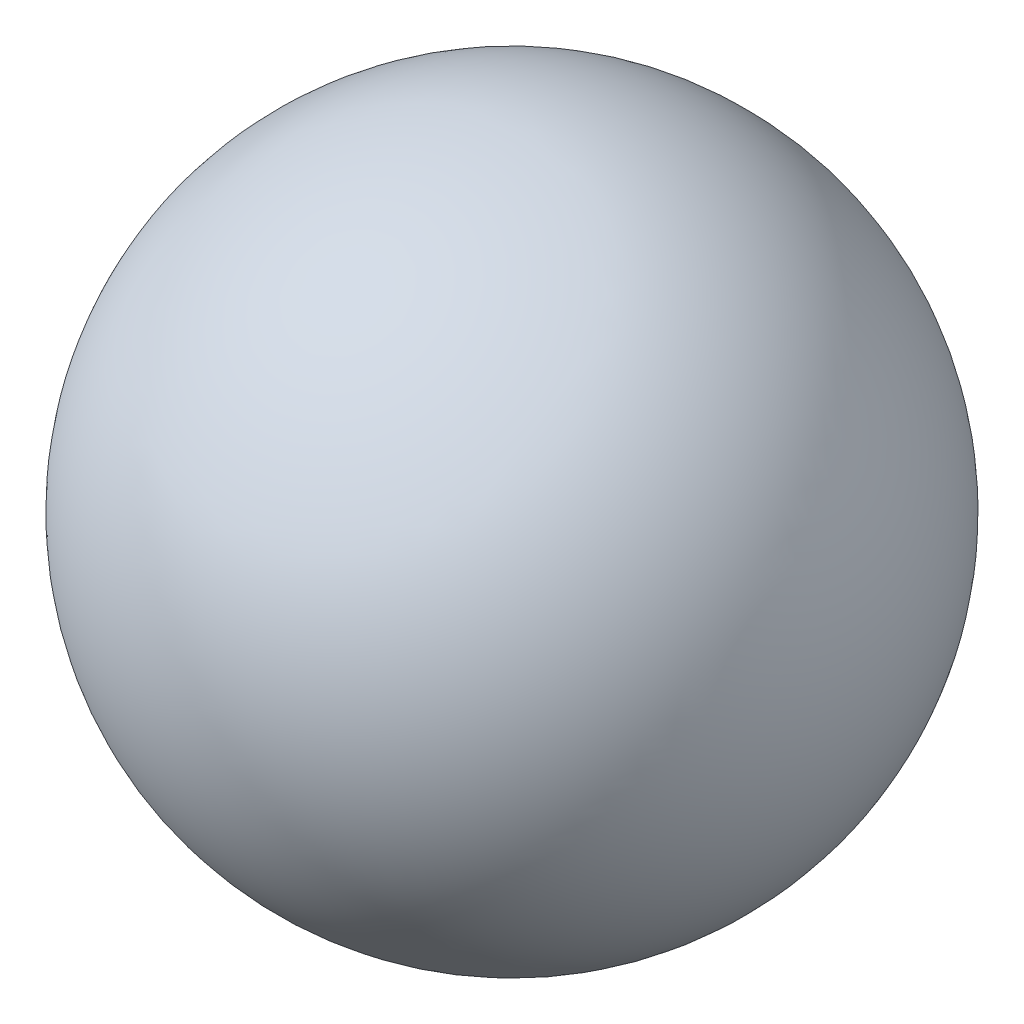
from build123d import *


with BuildPart() as part:
    # Sketch1 → Revolve2 (revolve)
    with BuildSketch(Plane.XY):
        with BuildLine():
            Line((0, 0), (0, 19))
            ThreePointArc((0, 19), (13.435028843, 13.435028843), (19, 0))
            Line((19, 0), (0, 0))
        make_face()
    revolve2 = revolve(axis=Axis((-54.760147601, 0, 0), (1, 0, 0)))

    # Mirror1: Revolve2 across plane
    add(revolve2.mirror(Plane(origin=(0, 0, 0), x_dir=(0, 0, 1), z_dir=(1, 0, 0))))


solid = part.part
